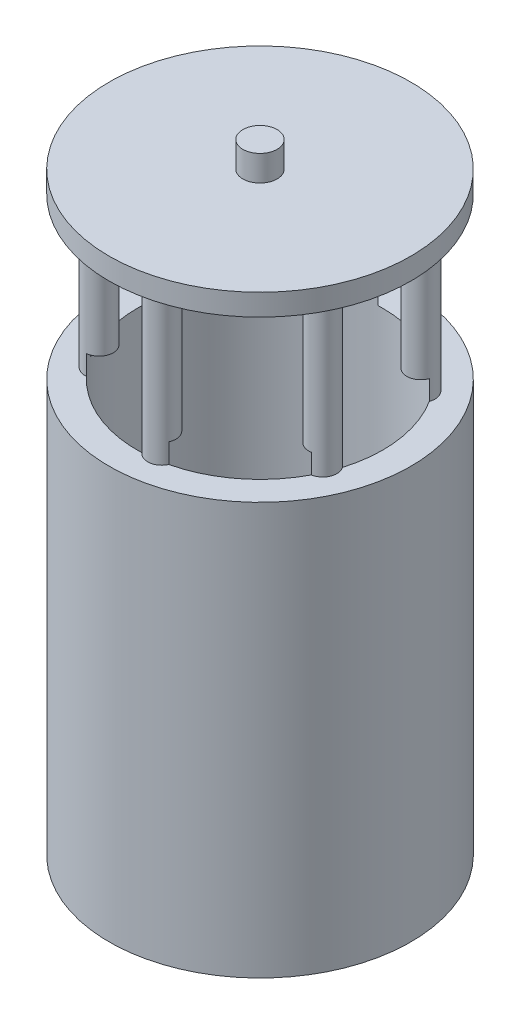
from build123d import *

# Parameters (mm, degrees)
SKETCH1_R           = 27.955
BOSS_EXTRUDE1_DEPTH = 4
SKETCH2_R           = 3.175
BOSS_EXTRUDE2_DEPTH = 4.76
SKETCH3_R           = 2.615316251
BOSS_EXTRUDE3_DEPTH = 29.718
SKETCH4_R           = 27.955
BOSS_EXTRUDE4_DEPTH = 76.35
SKETCH5_R           = 22.758745994
CUT_EXTRUDE1_DEPTH  = 80


with BuildPart() as part:
    # Sketch1 → Boss-Extrude1 (new body)
    with BuildSketch(Plane(origin=(0, 0, 0), x_dir=(1, 0, 0), z_dir=(0, 1, 0))):
        Circle(SKETCH1_R)
    extrude(amount=BOSS_EXTRUDE1_DEPTH)

    # Sketch2 → Boss-Extrude2 (add)
    with BuildSketch(Plane(origin=(0, 4, 0), x_dir=(1, 0, 0), z_dir=(0, 1, 0))):
        Circle(SKETCH2_R)
    extrude(amount=BOSS_EXTRUDE2_DEPTH)

    # Sketch3 → Boss-Extrude3 (add)
    with BuildSketch(Plane.XZ):
        with Locations((2.874048201, 21.060648295)):
            Circle(SKETCH3_R)
        with Locations((19.676080545, 8.041325394)):
            Circle(SKETCH3_R)
        with Locations((16.802032343, -13.019322902)):
            Circle(SKETCH3_R)
        with Locations((-2.874048201, -21.060648295)):
            Circle(SKETCH3_R)
        with Locations((-19.676080545, -8.041325394)):
            Circle(SKETCH3_R)
        with Locations((-16.802032343, 13.019322902)):
            Circle(SKETCH3_R)
    extrude(amount=BOSS_EXTRUDE3_DEPTH)

    # Sketch4 → Boss-Extrude4 (add)
    with BuildSketch(Plane.XZ.offset(29.718)):
        Circle(SKETCH4_R)
    extrude(amount=BOSS_EXTRUDE4_DEPTH)

    # Sketch5 → Cut-Extrude1 (cut)
    with BuildSketch(Plane.XZ.offset(106.068)):
        Circle(SKETCH5_R)
    extrude(amount=-CUT_EXTRUDE1_DEPTH, mode=Mode.SUBTRACT)


solid = part.part
